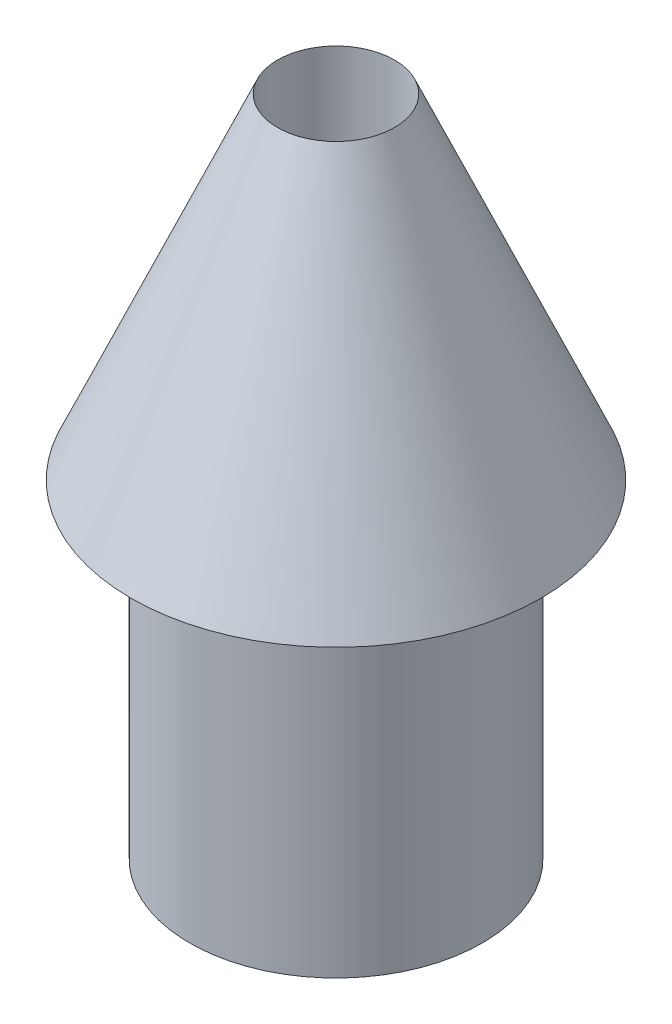
from build123d import *

# Parameters (mm, degrees)
ESQUISSE3_R             = 1.25
BOSS_EXTRU_1_DEPTH      = 2.8
ESQUISSE4_R             = 0.5
ENL_V_MAT_EXTRU_1_DEPTH = 13


with BuildPart() as part:
    # Esquisse1 → Révolution1 (revolve)
    with BuildSketch(Plane.XY, mode=Mode.PRIVATE) as r_volution1_sk:
        Polygon((0, 0), (1.75, 0), (0, 4), align=None)
    revolve(r_volution1_sk.sketch.rotate(Axis((0, 0, 0), (0, 1, 0)), 90), axis=Axis((0, 0, 0), (0, 1, 0)))  # turned: the seam where the file's is

    # Esquisse3 → Boss.-Extru.1 (add)
    with BuildSketch(Plane(origin=(0, 0, 0), x_dir=(-1, 0, 0), z_dir=(0, -1, 0))):
        with Locations(Location((0, 0, 0), (0, 0, 90))):  # turned: the seam where the file's is
            Circle(ESQUISSE3_R)
    extrude(amount=BOSS_EXTRU_1_DEPTH)

    # Esquisse4 → Enlèv. mat.-Extru.1 (cut)
    with BuildSketch(Plane.XZ.offset(2.8)):
        with Locations(Location((0, 0, 0), (0, 0, 270))):  # turned: the seam where the file's is
            Circle(ESQUISSE4_R)
    extrude(amount=-ENL_V_MAT_EXTRU_1_DEPTH, mode=Mode.SUBTRACT)


solid = part.part
